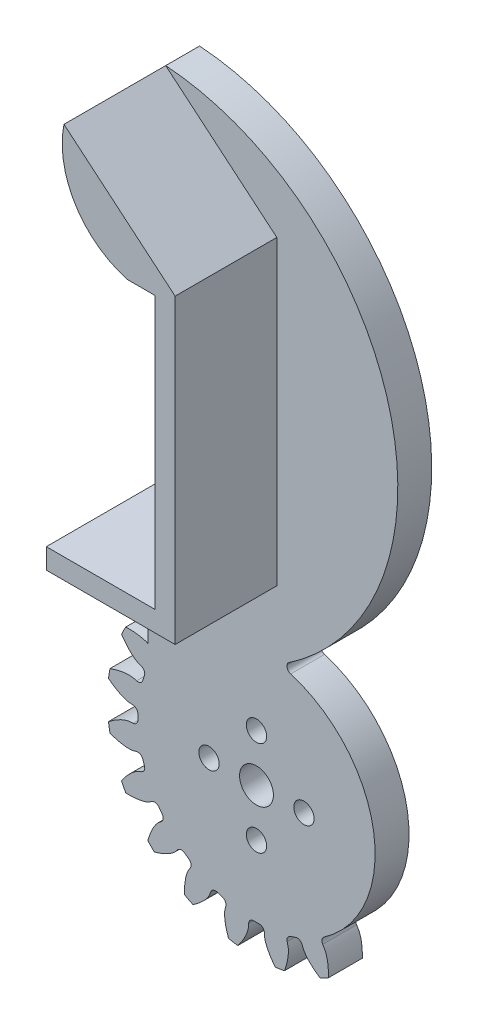
from build123d import *

# Parameters (mm, degrees)
SKETCH_1_R          = 22
LASHENA_DEPTH       = 5
CUT_EXTRUDEA_DEPTH  = 50
WWW_KYTOOL_CN_COUNT = 20
EXTRUDE_2_DEPTH     = 20
EXTRUDE_3_DEPTH     = 5
SKETCH_5_R          = 1.5
SKETCH_5_R_2        = 2.5
CUT_EXTRUDE_2_DEPTH = 5


with BuildPart() as part:
    # 草图1 → LaShenA (new body)
    with BuildSketch(Plane.XY):
        Circle(SKETCH_1_R)
    extrude(amount=LASHENA_DEPTH)

    # SketchA → Cut-ExtrudeA (cut)
    with BuildSketch(Plane.XY.offset(5)):
        with BuildLine():
            ThreePointArc((0.385333897, 17.495757137), (0, 17.5), (-0.385333897, 17.495757137))
            ThreePointArc((-0.385333897, 17.495757137), (-0.916561283, 17.696200843), (-1.1606309, 18.208851052))
            add(Edge.make_bspline(
                [(-1.1606309, 18.208851052), (-1.171930077, 18.392301345), (-1.176241251, 18.632580428), (-1.216058012, 18.896848962), (-1.240743696, 19.008516991), (-1.262518892, 19.096928039), (-1.290499427, 19.198195385), (-1.325289132, 19.312068627), (-1.3676305, 19.438230848), (-1.418205326, 19.576348168), (-1.477697907, 19.726054242), (-1.546773605, 19.886955785), (-1.626084178, 20.058631495), (-1.716264818, 20.240633083), (-1.81793375, 20.432485693), (-1.931691083, 20.633688556), (-2.058117912, 20.843715613), (-2.197775372, 21.062016196), (-2.351203737, 21.28801573), (-2.518921525, 21.521116464), (-2.701424703, 21.760698239), (-2.899185586, 22.006119297), (-3.189864756, 22.34735877), (-3.423201244, 22.599173394), (-3.58629474, 22.766196042)],
                knots=[0.125068197, 0.125068197, 0.125068197, 0.125068197, 0.215847125, 0.244833276, 0.257593391, 0.272673526, 0.290073681, 0.309793857, 0.331834054, 0.356194271, 0.382874509, 0.411874767, 0.443195046, 0.476835345, 0.512795666, 0.551076006, 0.591676368, 0.634596749, 0.679837152, 0.727397575, 0.777278019, 0.829478483, 0.883998968, 1, 1, 1, 1], degree=3))
            ThreePointArc((-3.58629474, 22.766196042), (0, 23.046934551), (3.58629474, 22.766196042))
            add(Edge.make_bspline(
                [(1.1606309, 18.208851052), (1.171930077, 18.392301345), (1.176241251, 18.632580428), (1.216058012, 18.896848962), (1.240743696, 19.008516991), (1.262518892, 19.096928039), (1.290499427, 19.198195385), (1.325289132, 19.312068627), (1.3676305, 19.438230848), (1.418205326, 19.576348168), (1.477697907, 19.726054242), (1.546773605, 19.886955785), (1.626084178, 20.058631495), (1.716264818, 20.240633083), (1.81793375, 20.432485693), (1.931691083, 20.633688556), (2.058117912, 20.843715613), (2.197775372, 21.062016196), (2.351203737, 21.28801573), (2.518921525, 21.521116464), (2.701424703, 21.760698239), (2.899185586, 22.006119297), (3.189864756, 22.34735877), (3.423201244, 22.599173394), (3.58629474, 22.766196042)],
                knots=[0.125068197, 0.125068197, 0.125068197, 0.125068197, 0.215847125, 0.244833276, 0.257593391, 0.272673526, 0.290073681, 0.309793857, 0.331834054, 0.356194271, 0.382874509, 0.411874767, 0.443195046, 0.476835345, 0.512795666, 0.551076006, 0.591676368, 0.634596749, 0.679837152, 0.727397575, 0.777278019, 0.829478483, 0.883998968, 1, 1, 1, 1], degree=3))
            ThreePointArc((1.1606309, 18.208851052), (0.916561283, 17.696200843), (0.385333897, 17.495757137))
        make_face()
    cut_extrudea = extrude(amount=-CUT_EXTRUDEA_DEPTH, mode=Mode.SUBTRACT)

    # www.KYTool.cn: Cut-ExtrudeA ×20 about axis
    www_kytool_cn_axis = Axis((0, 0, -88.99), (0, 0, 1))
    for i in range(1, WWW_KYTOOL_CN_COUNT):
        add(cut_extrudea.rotate(www_kytool_cn_axis, i * 360 / WWW_KYTOOL_CN_COUNT), mode=Mode.SUBTRACT)

    # 草图4 → 凸台-拉伸3 (add)
    with BuildSketch(Plane(origin=(0, 0, 0), x_dir=(-1, 0, 0), z_dir=(0, 0, -1))):
        with BuildLine():
            Line((16, 27), (16, 8.586439847))
            Line((16, 8.586439847), (11.899995844, 8.586439847))
            Line((11.899995844, 8.586439847), (11.899995844, 11.882558972))
            ThreePointArc((11.899995844, 11.882558972), (-20.838640796, 49.249376986), (13.392526033, 85.253885523))
            Line((13.392526033, 85.253885523), (-3, 71.498922974))
            Line((-3, 71.498922974), (-3, 27))
            Line((-3, 27), (16, 27))
        make_face()
    extrude(amount=-EXTRUDE_3_DEPTH)

    # 草图5 → 切除-拉伸2 (cut)
    with BuildSketch(Plane(origin=(0, 0, 0), x_dir=(-1, 0, 0), z_dir=(0, 0, -1))):
        with Locations((-7, 0)):
            Circle(SKETCH_5_R)
        with Locations((0, 7)):
            Circle(SKETCH_5_R)
        with Locations((7, 0)):
            Circle(SKETCH_5_R)
        with Locations((0, -7)):
            Circle(SKETCH_5_R)
        Circle(SKETCH_5_R_2)
        with BuildLine():
            Line((-5.772960598, 16.52037911), (-8.967977297, 20.552307221))
            Line((-8.967977297, 20.552307221), (-16.195440918, 18.536343166))
            Line((-16.195440918, 18.536343166), (-27.892520199, -3.792833397))
            Line((-27.892520199, -3.792833397), (-14.673869629, -19.198742695))
            Line((-14.673869629, -19.198742695), (-10.286241915, -14.157797402))
            ThreePointArc((-10.286241915, -14.157797402), (-17.31363985, 2.547130767), (-5.772960598, 16.52037911))
        make_face()
    extrude(amount=-CUT_EXTRUDE_2_DEPTH, mode=Mode.SUBTRACT)


with BuildPart() as body_2:
    # 草图3 → 凸台-拉伸2 (new body)
    with BuildSketch(Plane(origin=(0, 0, 0), x_dir=(-1, 0, 0), z_dir=(0, 0, -1))):
        with BuildLine():
            Line((0, 70.1), (4, 70.1))
            ThreePointArc((4, 70.1), (11.703223048, 75.813199609), (13.392526033, 85.253885523))
            Line((13.392526033, 85.253885523), (-3, 71.498922974))
            Line((-3, 71.498922974), (-3, 27))
            Line((-3, 27), (13, 27))
            Line((13, 27), (16, 27))
            Line((16, 27), (16, 30))
            Line((16, 30), (0, 30))
            Line((0, 30), (0, 70.1))
        make_face()
    extrude(amount=-EXTRUDE_2_DEPTH)


solid = Compound([part.part, body_2.part])
